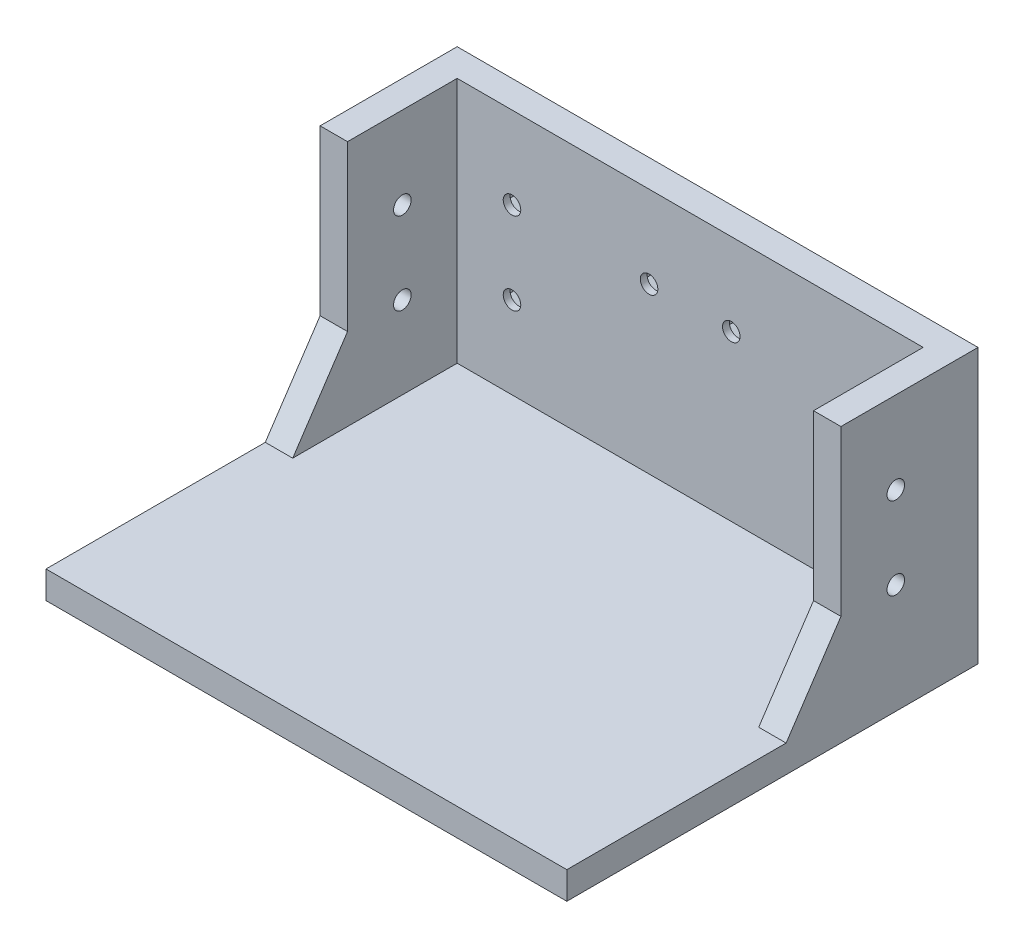
from build123d import *

# Parameters (mm, degrees)
SKETCH1_W               = 95
SKETCH1_H               = 75
BOSS_EXTRUDE1_DEPTH     = 5
BOSS_EXTRUDE4_DEPTH     = 45
SKETCH5_R               = 1.6
CUT_EXTRUDE1_DEPTH      = 91
CUT_EXTRUDE1_DEPTH_BACK = 6
CUT_EXTRUDE2_REACH      = 7
SKETCH6_R               = 1.6
BOSS_EXTRUDE5_DEPTH     = 5
BOSS_EXTRUDE6_START     = -90
BOSS_EXTRUDE6_DEPTH     = 5
CUT_EXTRUDE3_REACH      = 77
SKETCH8_R               = 1.6
CUT_EXTRUDE4_START      = -1.25
CUT_EXTRUDE4_DEPTH      = 2.5


with BuildPart() as part:
    # Sketch1 → Boss-Extrude1 (new body)
    with BuildSketch(Plane(origin=(0, 0, 0), x_dir=(1, 0, 0), z_dir=(0, 1, 0))):
        Rectangle(SKETCH1_W, SKETCH1_H)
    extrude(amount=BOSS_EXTRUDE1_DEPTH)

    # Sketch4 → Boss-Extrude4 (add)
    with BuildSketch(Plane(origin=(0, 5, 0), x_dir=(1, 0, 0), z_dir=(0, 1, 0))):
        Polygon((-47.5, 37.5), (-42.5, 37.5), (42.5, 37.5), (47.5, 37.5), (47.5, 12.5), (42.5, 12.5), (42.5, 32.5), (-42.5, 32.5), (-42.5, 12.5), (-47.5, 12.5), align=None)
    extrude(amount=BOSS_EXTRUDE4_DEPTH)

    # Sketch5 → Cut-Extrude1 (cut, two sides)
    with BuildSketch(Plane(origin=(-42.5, 0, 0), x_dir=(0, 0, -1), z_dir=(1, 0, 0))) as cut_extrude1_sk:
        with Locations((22.5, 35)):
            Circle(SKETCH5_R)
        with Locations((22.5, 20)):
            Circle(SKETCH5_R)
    extrude(amount=CUT_EXTRUDE1_DEPTH, mode=Mode.SUBTRACT)
    extrude(cut_extrude1_sk.sketch, amount=-CUT_EXTRUDE1_DEPTH_BACK, mode=Mode.SUBTRACT)

    # Sketch6 → Cut-Extrude2 (cut, up to next)
    with BuildSketch(Plane.XY.offset(-32.5), mode=Mode.PRIVATE) as cut_extrude2_sk1:
        with Locations((-32.5, 35)):
            Circle(SKETCH6_R)
    cut_extrude2_tool1 = extrude(cut_extrude2_sk1.sketch, amount=-CUT_EXTRUDE2_REACH, mode=Mode.PRIVATE) & part.part
    add(cut_extrude2_tool1.solids().sort_by_distance((-32.5, 35, -32.5))[0], mode=Mode.SUBTRACT)
    # Sketch6 → Cut-Extrude2 (cut, up to next)
    with BuildSketch(Plane.XY.offset(-32.5), mode=Mode.PRIVATE) as cut_extrude2_sk2:
        with Locations((-32.5, 20)):
            Circle(SKETCH6_R)
    cut_extrude2_tool2 = extrude(cut_extrude2_sk2.sketch, amount=-CUT_EXTRUDE2_REACH, mode=Mode.PRIVATE) & part.part
    add(cut_extrude2_tool2.solids().sort_by_distance((-32.5, 20, -32.5))[0], mode=Mode.SUBTRACT)
    # Sketch6 → Cut-Extrude2 (cut, up to next)
    with BuildSketch(Plane.XY.offset(-32.5), mode=Mode.PRIVATE) as cut_extrude2_sk3:
        with Locations((32.5, 20)):
            Circle(SKETCH6_R)
    cut_extrude2_tool3 = extrude(cut_extrude2_sk3.sketch, amount=-CUT_EXTRUDE2_REACH, mode=Mode.PRIVATE) & part.part
    add(cut_extrude2_tool3.solids().sort_by_distance((32.5, 20, -32.5))[0], mode=Mode.SUBTRACT)
    # Sketch6 → Cut-Extrude2 (cut, up to next)
    with BuildSketch(Plane.XY.offset(-32.5), mode=Mode.PRIVATE) as cut_extrude2_sk4:
        with Locations((32.5, 35)):
            Circle(SKETCH6_R)
    cut_extrude2_tool4 = extrude(cut_extrude2_sk4.sketch, amount=-CUT_EXTRUDE2_REACH, mode=Mode.PRIVATE) & part.part
    add(cut_extrude2_tool4.solids().sort_by_distance((32.5, 35, -32.5))[0], mode=Mode.SUBTRACT)

    # Sketch7 → Boss-Extrude5 (add)
    with BuildSketch(Plane.ZY.offset(47.5)):
        Polygon((-12.5, 5), (-2.5, 5), (-12.5, 20), align=None)
    extrude(amount=-BOSS_EXTRUDE5_DEPTH)

    # Sketch7_2 → Boss-Extrude6 (add)
    with BuildSketch(Plane.ZY.offset(47.5).offset(BOSS_EXTRUDE6_START)):
        Polygon((-12.5, 5), (-2.5, 5), (-12.5, 20), align=None)
    extrude(amount=-BOSS_EXTRUDE6_DEPTH)

    # Sketch8 → Cut-Extrude3 (cut, up to next)
    with BuildSketch(Plane(origin=(0, 0, -37.5), x_dir=(-1, 0, 0), z_dir=(0, 0, -1)), mode=Mode.PRIVATE) as cut_extrude3_sk1:
        with Locations((-7.5, 35)):
            Circle(SKETCH8_R)
    cut_extrude3_tool1 = extrude(cut_extrude3_sk1.sketch, amount=-CUT_EXTRUDE3_REACH, mode=Mode.PRIVATE) & part.part
    add(cut_extrude3_tool1.solids().sort_by_distance((7.5, 35, -37.5))[0], mode=Mode.SUBTRACT)
    # Sketch8 → Cut-Extrude3 (cut, up to next)
    with BuildSketch(Plane(origin=(0, 0, -37.5), x_dir=(-1, 0, 0), z_dir=(0, 0, -1)), mode=Mode.PRIVATE) as cut_extrude3_sk2:
        with Locations((7.5, 35)):
            Circle(SKETCH8_R)
    cut_extrude3_tool2 = extrude(cut_extrude3_sk2.sketch, amount=-CUT_EXTRUDE3_REACH, mode=Mode.PRIVATE) & part.part
    add(cut_extrude3_tool2.solids().sort_by_distance((-7.5, 35, -37.5))[0], mode=Mode.SUBTRACT)

    # Sketch9 → Cut-Extrude4 (cut)
    with BuildSketch(Plane(origin=(0, 0, -37.5), x_dir=(-1, 0, 0), z_dir=(0, 0, -1)).offset(CUT_EXTRUDE4_START)):
        Polygon((-32.5, 38.435234102), (-35.475, 36.717617051), (-35.475, 33.282382949), (-32.5, 31.564765898), (-29.525, 33.282382949), (-29.525, 36.717617051), align=None)
        Polygon((-7.5, 38.435234102), (-10.475, 36.717617051), (-10.475, 33.282382949), (-7.5, 31.564765898), (-4.525, 33.282382949), (-4.525, 36.717617051), align=None)
        Polygon((7.5, 38.435234102), (4.525, 36.717617051), (4.525, 33.282382949), (7.5, 31.564765898), (10.475, 33.282382949), (10.475, 36.717617051), align=None)
        Polygon((32.5, 38.435234102), (29.525, 36.717617051), (29.525, 33.282382949), (32.5, 31.564765898), (35.475, 33.282382949), (35.475, 36.717617051), align=None)
        Polygon((32.5, 23.435234102), (29.525, 21.717617051), (29.525, 18.282382949), (32.5, 16.564765898), (35.475, 18.282382949), (35.475, 21.717617051), align=None)
        Polygon((-32.5, 23.435234102), (-35.475, 21.717617051), (-35.475, 18.282382949), (-32.5, 16.564765898), (-29.525, 18.282382949), (-29.525, 21.717617051), align=None)
    extrude(amount=-CUT_EXTRUDE4_DEPTH, mode=Mode.SUBTRACT)


solid = part.part
